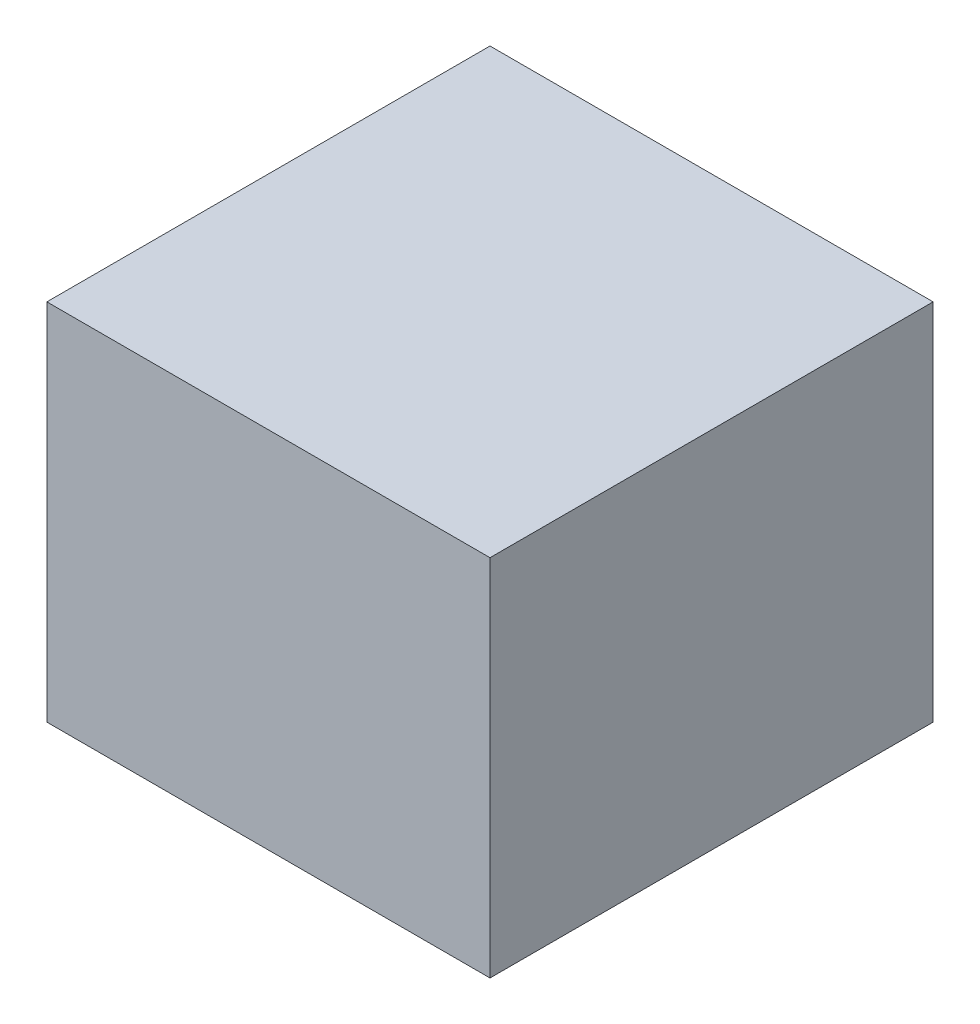
from build123d import *

# Parameters (mm, degrees)
SKETCH_1_W      = 140
SKETCH_1_H      = 140
EXTRUDE_1_DEPTH = 57.5


with BuildPart() as part:
    # 草图1 → 凸台-拉伸1 (new body, symmetric)
    with BuildSketch(Plane(origin=(0, 0, 0), x_dir=(1, 0, 0), z_dir=(0, 1, 0))):
        Rectangle(SKETCH_1_W, SKETCH_1_H)
    extrude(amount=EXTRUDE_1_DEPTH, both=True)


solid = part.part
